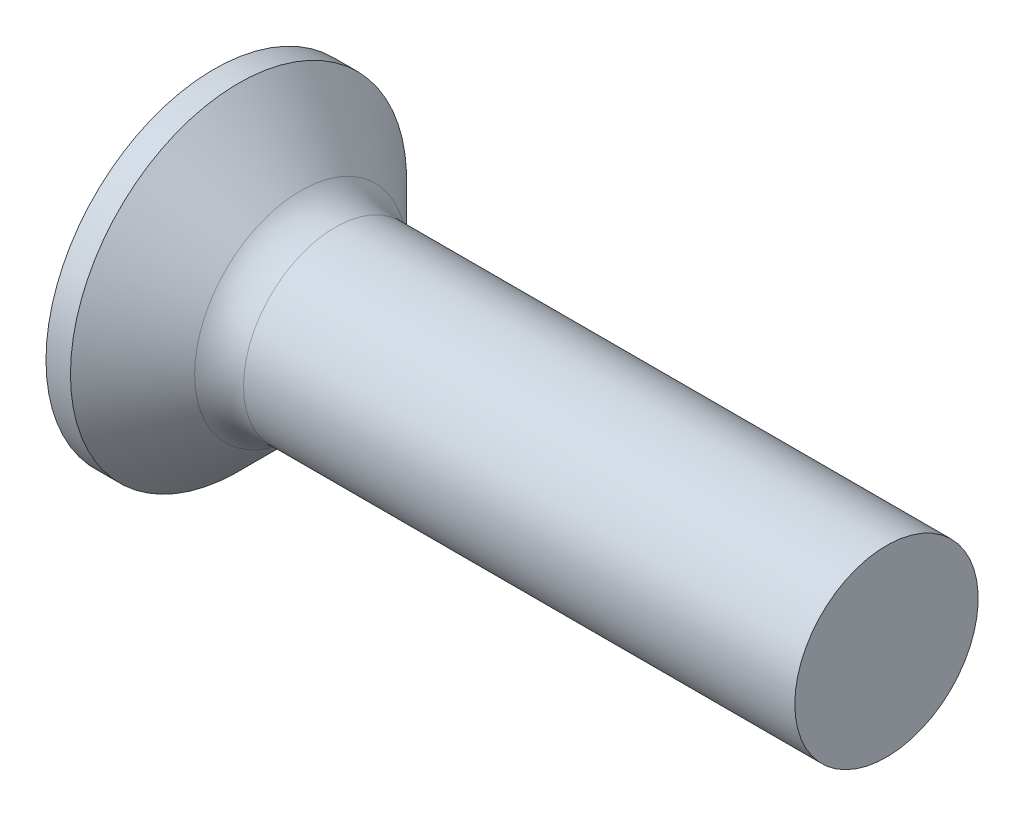
from build123d import *

# Parameters (mm, degrees)
FILLET1_R    = 0.8
SKETCH3_W    = 0.74
SKETCH3_H    = 3
SKETCH4_W    = 0.74
SKETCH4_H    = 0.99570227
RECPAT_COUNT = 2
RECPAT_ANGLE = 90


with BuildPart() as part:
    # BodySke → Base-Revolve (revolve)
    with BuildSketch(Plane.XY):
        Polygon((0, 0), (0, 2.75), (0.4, 2.75), (1.65, 1.5), (11, 1.5), (11, 0), align=None)
    revolve(axis=Axis((-6.35, 0, 0), (1, 0, 0)))

    # Fillet1
    fillet1_edges = [part.edges().sort_by_distance(p)[0] for p in [
        (1.65, -1.5, 0),
    ]]
    fillet(fillet1_edges, radius=FILLET1_R)

    # Sketch3 → Recess section 0
    with BuildSketch(Plane.ZY):
        Rectangle(SKETCH3_W, SKETCH3_H)
    # Sketch4 → Recess section 1
    with BuildSketch(Plane.ZY.offset(-2.01)):
        Rectangle(SKETCH4_W, SKETCH4_H)
    recess = loft(mode=Mode.SUBTRACT)

    # RecPat: Recess ×2 about axis
    recpat_axis = Axis((0, 0, 0), (1, 0, 0))
    for i in range(1, RECPAT_COUNT):
        add(recess.rotate(recpat_axis, i * RECPAT_ANGLE / (RECPAT_COUNT - 1)), mode=Mode.SUBTRACT)

    # RecCorSke → RecessCore (revolve, cut)
    with BuildSketch(Plane.XY):
        Polygon((0, 0), (0, 0.696552892), (2.01, 0.556), (2.190655351, 0), align=None)
    revolve(axis=Axis((-3.175, 0, 0), (1, 0, 0)), mode=Mode.SUBTRACT)


solid = part.part
